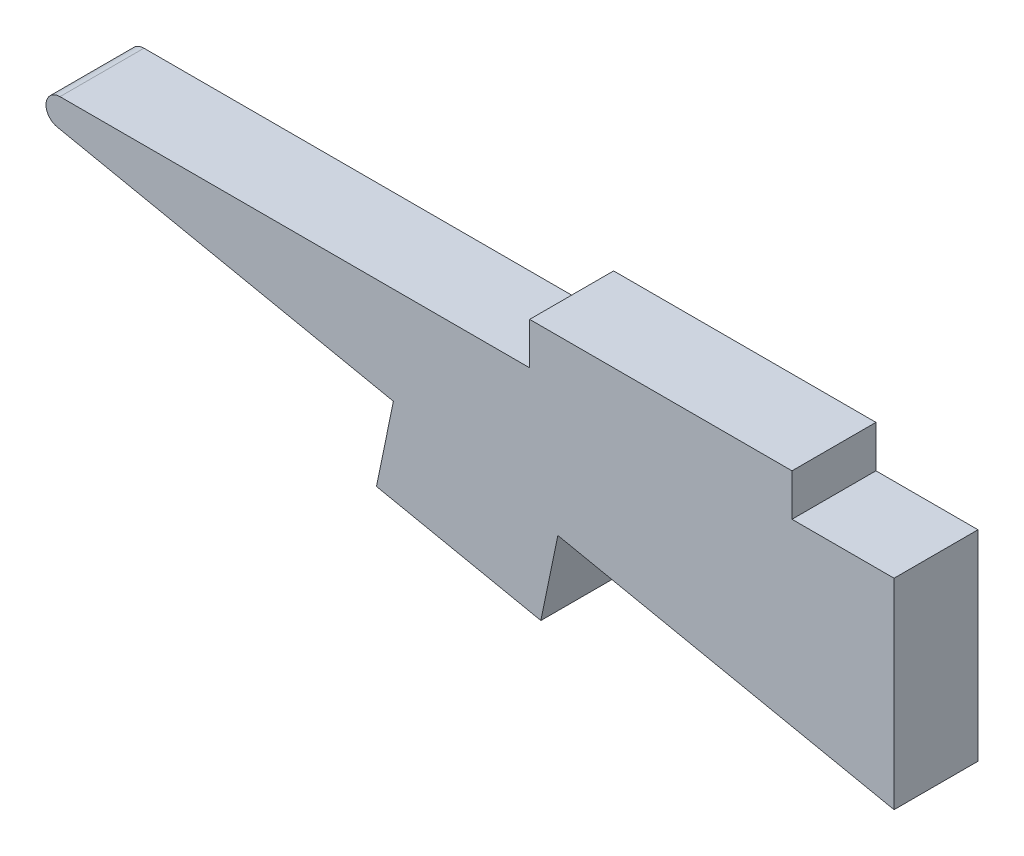
from build123d import *

# Parameters (mm, degrees)
BOSS_EXTRUDE1_DEPTH = 1.524
FILLET1_R           = 0.254


with BuildPart() as part:
    # Sketch1 → Boss-Extrude1 (new body)
    with BuildSketch(Plane.XY):
        Polygon((-6.2865, -0.762), (-6.2865, -1.524), (-4.433524529, -1.524), (-4.433524529, -5.163998713), (-10.537505967, -3.903634867), (-10.84568392, -5.39615031), (-13.830714807, -4.779794404), (-13.522536854, -3.287278961), (-22.062151888, -1.524), (-11.049, -1.524), (-11.049, -0.762), align=None)
    extrude(amount=BOSS_EXTRUDE1_DEPTH)

    # Fillet1
    fillet1_edges = [part.edges().sort_by_distance(p)[0] for p in [
        (-22.062151888, -1.524, 0.762),
    ]]
    fillet(fillet1_edges, radius=FILLET1_R)


solid = part.part
